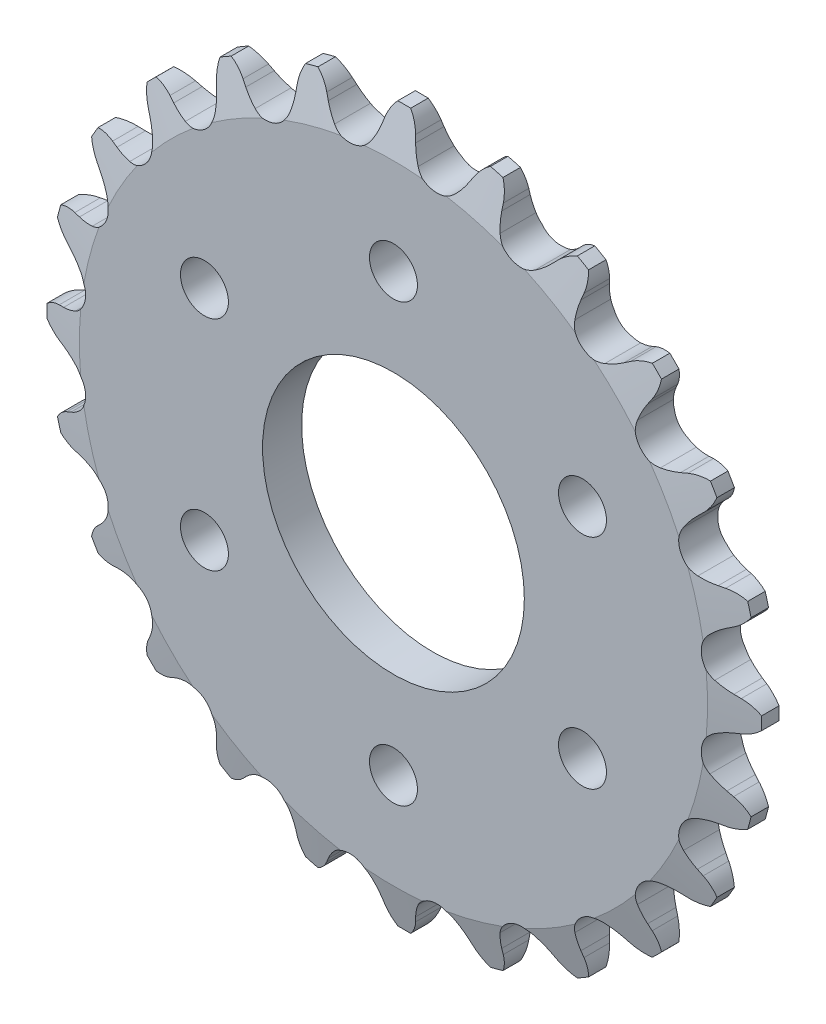
from build123d import *

# Parameters (mm, degrees)
CUT_EXTRUDE1_DEPTH      = 56.241197044
CIRPATTERN1_COUNT       = 24
CUT_EXTRUDE2_DEPTH      = 56.241197189
CUT_EXTRUDE2_DEPTH_BACK = 56.241197189
SKETCH3_OUTSIDE_W       = 102.16
SKETCH3_OUTSIDE_H       = 102.16
SKETCH3_OUTSIDE_R       = 38.989
SKETCH3_OUTSIDE_R_2     = 14.28115
SKETCH4_R               = 2.6162
CUT_EXTRUDE3_DEPTH      = 56.30364594


with BuildPart() as part:
    # Sketch1 → Revolve1 (revolve)
    with BuildSketch(Plane(origin=(0, 0, 0), x_dir=(0, 0, -1), z_dir=(1, 0, 0)), mode=Mode.PRIVATE) as revolve1_sk:
        Polygon((2.1336, 0), (-2.1336, 0), (-2.1336, 34.269778962), (-0.942975, 39.032278962), (0.942975, 39.032278962), (2.1336, 34.269778962), align=None)
    revolve(revolve1_sk.sketch.rotate(Axis((0, 0, -2.1336), (0, 0, 1)), 90), axis=Axis((0, 0, -2.1336), (0, 0, 1)))

    # Sketch0 → Cut-Extrude1 (cut, symmetric)
    with BuildSketch(Plane.XY):
        with BuildLine():
            Line((8.015274683, -36.366529581), (7.690368958, -35.788342824))
            ThreePointArc((7.690368958, -35.788342824), (7.191905212, -35.028059262), (6.594472249, -34.342806713))
            ThreePointArc((6.594472249, -34.342806713), (4.424332741, -33.606143615), (2.518801384, -34.879378962))
            ThreePointArc((2.518801384, -34.879378962), (2.119081865, -35.695909125), (1.834378726, -36.559298564))
            Line((1.834378726, -36.559298564), (1.670189638, -37.201875875))
            ThreePointArc((1.670189638, -37.201875875), (0.08767712, -39.532307896), (-2.618394346, -40.314891121))
            ThreePointArc((-2.618394346, -40.314891121), (5.273236252, -40.054205952), (12.963436345, -38.263504193))
            ThreePointArc((12.963436345, -38.263504193), (10.147024586, -38.207969678), (8.015274683, -36.366529581))
        make_face()
    cut_extrude1 = extrude(amount=CUT_EXTRUDE1_DEPTH, both=True, mode=Mode.SUBTRACT)

    # CirPattern1: Cut-Extrude1 ×24 about axis
    cirpattern1_axis = Axis((0, 0, 0), (0, 0, 1))
    for i in range(1, CIRPATTERN1_COUNT):
        add(cut_extrude1.rotate(cirpattern1_axis, i * 360 / CIRPATTERN1_COUNT), mode=Mode.SUBTRACT)

    # Sketch3 outside → Cut-Extrude2 (cut, two sides: drawn at the far end of the back side and taken through both)
    # profile 1 of 2: a face of its own
    with BuildSketch(Plane.XY.offset(-CUT_EXTRUDE2_DEPTH_BACK)):
        Rectangle(SKETCH3_OUTSIDE_W, SKETCH3_OUTSIDE_H)
        Circle(SKETCH3_OUTSIDE_R, mode=Mode.SUBTRACT)
    # profile 2 of 2: a face of its own
    with BuildSketch(Plane.XY.offset(-CUT_EXTRUDE2_DEPTH_BACK)):
        Circle(SKETCH3_OUTSIDE_R_2)
    extrude(amount=CUT_EXTRUDE2_DEPTH + CUT_EXTRUDE2_DEPTH_BACK, mode=Mode.SUBTRACT)

    # Sketch4 → Cut-Extrude3 (cut, through all)
    with BuildSketch(Plane.XY.offset(2.1336)):
        with Locations((0, 23.8125)):
            Circle(SKETCH4_R)
        with Locations((20.622229928, 11.90625)):
            Circle(SKETCH4_R)
        with Locations((20.622229928, -11.90625)):
            Circle(SKETCH4_R)
        with Locations((0, -23.8125)):
            Circle(SKETCH4_R)
        with Locations((-20.622229928, -11.90625)):
            Circle(SKETCH4_R)
        with Locations((-20.622229928, 11.90625)):
            Circle(SKETCH4_R)
    extrude(amount=-CUT_EXTRUDE3_DEPTH, mode=Mode.SUBTRACT)


solid = part.part
